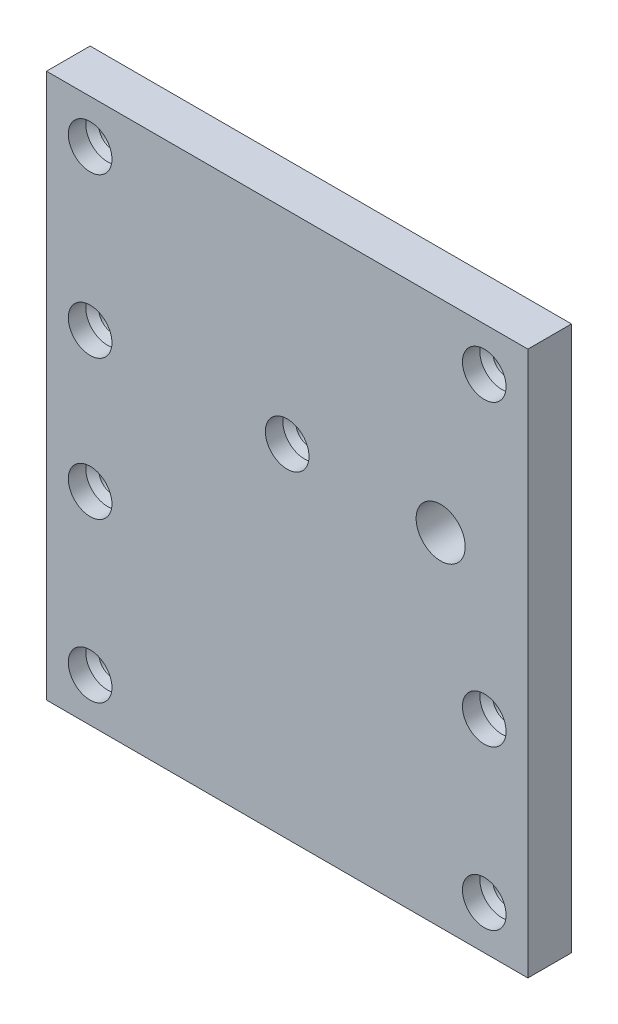
from build123d import *

# Parameters (mm, degrees)
SKETCH1_W                        = 35.042145822
SKETCH1_H                        = 39.6494
BOSS_EXTRUDE1_DEPTH              = 3.175
F_9_64_0_14063_DIAMETER_HOLE1_D  = 3.572002
F_5_64_0_07813_DIAMETER_HOLE1_D  = 1.984502
F_1_8_0_125_DIAMETER_HOLE1_D     = 3.175
F_1_8_0_125_DIAMETER_HOLE1_DEPTH = 1.27
F_1_8_0_125_DIAMETER_HOLE1_TIP   = 0.953866233


with BuildPart() as part:
    # Sketch1 → Boss-Extrude1 (new body)
    with BuildSketch(Plane.XY):
        with Locations((2.821072911, 35.354563982)):
            Rectangle(SKETCH1_W, SKETCH1_H)
    extrude(amount=BOSS_EXTRUDE1_DEPTH)

    # 9/64 (0.14063) Diameter Hole1 (through all)
    with Locations(Plane.XY.offset(3.175)):
        with Locations((13.992145822, 40.434563982)):
            Hole(F_9_64_0_14063_DIAMETER_HOLE1_D / 2)

    # 5/64 (0.07813) Diameter Hole1 (through all)
    with Locations(Plane.XY.offset(3.175)):
        with Locations((-11.525, 40.434563982), (-11.525, 52.004263982), (17.167145822, 52.004263982), (2.821072911, 40.434563982), (-11.525, 30.274563982), (-11.525, 18.704863982), (17.167145822, 18.704863982), (17.167145822, 30.274563982)):
            Hole(F_5_64_0_07813_DIAMETER_HOLE1_D / 2)

    # 1/8 (0.125) Diameter Hole1
    with Locations(Plane.XY.offset(3.175)):
        with Locations((17.167145822, 18.704863982), (-11.525, 18.704863982), (-11.525, 30.274563982), (17.167145822, 30.274563982), (2.821072911, 40.434563982), (-11.525, 40.434563982), (17.167145822, 52.004263982), (-11.525, 52.004263982)):
            Hole(F_1_8_0_125_DIAMETER_HOLE1_D / 2, depth=F_1_8_0_125_DIAMETER_HOLE1_DEPTH)
            with Locations((0, 0, -(F_1_8_0_125_DIAMETER_HOLE1_DEPTH + F_1_8_0_125_DIAMETER_HOLE1_TIP / 2))):  # 118° drill point
                Cone(0, F_1_8_0_125_DIAMETER_HOLE1_D / 2, F_1_8_0_125_DIAMETER_HOLE1_TIP, mode=Mode.SUBTRACT)


solid = part.part
